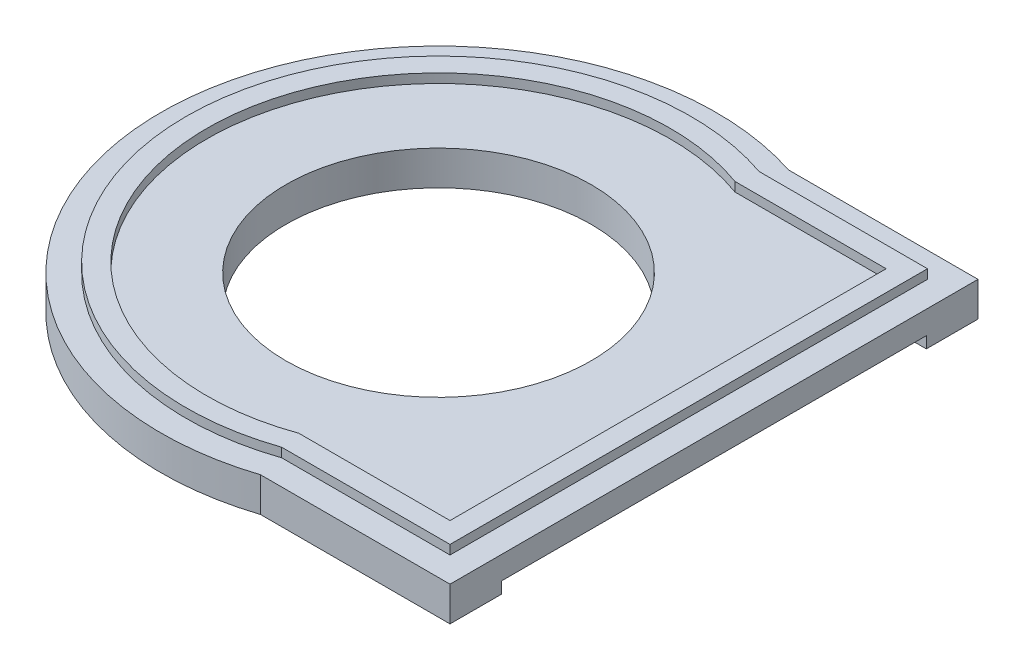
from build123d import *

# Parameters (mm, degrees)
SKETCH_1_R            = 6.65
EXTRUDE_1_DEPTH       = 1.5
SKETCH_2_W            = 3.35
SKETCH_2_H            = 18.5
CUT_EXTRUDE_1_DEPTH   = 0.5
EXTRUDE_1_2_DEPTH     = 0.4
CUT_EXTRUDE_1_2_DEPTH = 0.4


with BuildPart() as part:
    # Эскиз1 → Extrude 1 (new body)
    with BuildSketch(Plane(origin=(0, 0, 0), x_dir=(1, 0, 0), z_dir=(0, 1, 0))):
        with BuildLine():
            Line((3.746255484, -11.5), (12, -11.5))
            Line((12, -11.5), (12, 11.5))
            Line((12, 11.5), (7.873127742, 11.5))
            Line((7.873127742, 11.5), (3.746255484, 11.5))
            ThreePointArc((3.746255484, 11.5), (-12.09481005, 0), (3.746255484, -11.5))
        make_face()
        Circle(SKETCH_1_R, mode=Mode.SUBTRACT)
    extrude(amount=EXTRUDE_1_DEPTH)

    # Эскиз2 → Cut-Extrude 1 (cut)
    with BuildSketch(Plane.XZ):
        with Locations((10.325, 0)):
            Rectangle(SKETCH_2_W, SKETCH_2_H)
    extrude(amount=-CUT_EXTRUDE_1_DEPTH, mode=Mode.SUBTRACT)

    # Эскиз3 → Extrude 1 2 (add)
    with BuildSketch(Plane(origin=(0, 1.5, 0), x_dir=(1, 0, 0), z_dir=(0, 1, 0))):
        with BuildLine():
            Line((3.746255484, -11.5), (12, -11.5))
            Line((12, -11.5), (12, 11.5))
            Line((12, 11.5), (3.746255484, 11.5))
            ThreePointArc((3.746255484, 11.5), (-12.09481005, 0), (3.746255484, -11.5))
        make_face()
        with BuildLine():
            Line((3.413969823, -9.5), (10, -9.5))
            Line((10, -9.5), (10, 9.5))
            Line((10, 9.5), (3.413969823, 9.5))
            ThreePointArc((3.413969823, 9.5), (-10.09481005, 0), (3.413969823, -9.5))
        make_face(mode=Mode.SUBTRACT)
    extrude(amount=EXTRUDE_1_2_DEPTH)

    # Эскиз4 → Cut-Extrude 1 2 (cut)
    with BuildSketch(Plane(origin=(0, 1.9, 0), x_dir=(1, 0, 0), z_dir=(0, 1, 0))):
        with BuildLine():
            Line((3.746255484, -11.5), (12, -11.5))
            Line((12, -11.5), (12, 11.5))
            Line((12, 11.5), (3.746255484, 11.5))
            ThreePointArc((3.746255484, 11.5), (-12.09481005, 0), (3.746255484, -11.5))
        make_face()
        with BuildLine():
            Line((3.56733066, -10.4), (10.9, -10.4))
            Line((10.9, -10.4), (10.9, 10.4))
            Line((10.9, 10.4), (3.56733066, 10.4))
            ThreePointArc((3.56733066, 10.4), (-10.99481005, 0), (3.56733066, -10.4))
        make_face(mode=Mode.SUBTRACT)
    extrude(amount=-CUT_EXTRUDE_1_2_DEPTH, mode=Mode.SUBTRACT)


solid = part.part
